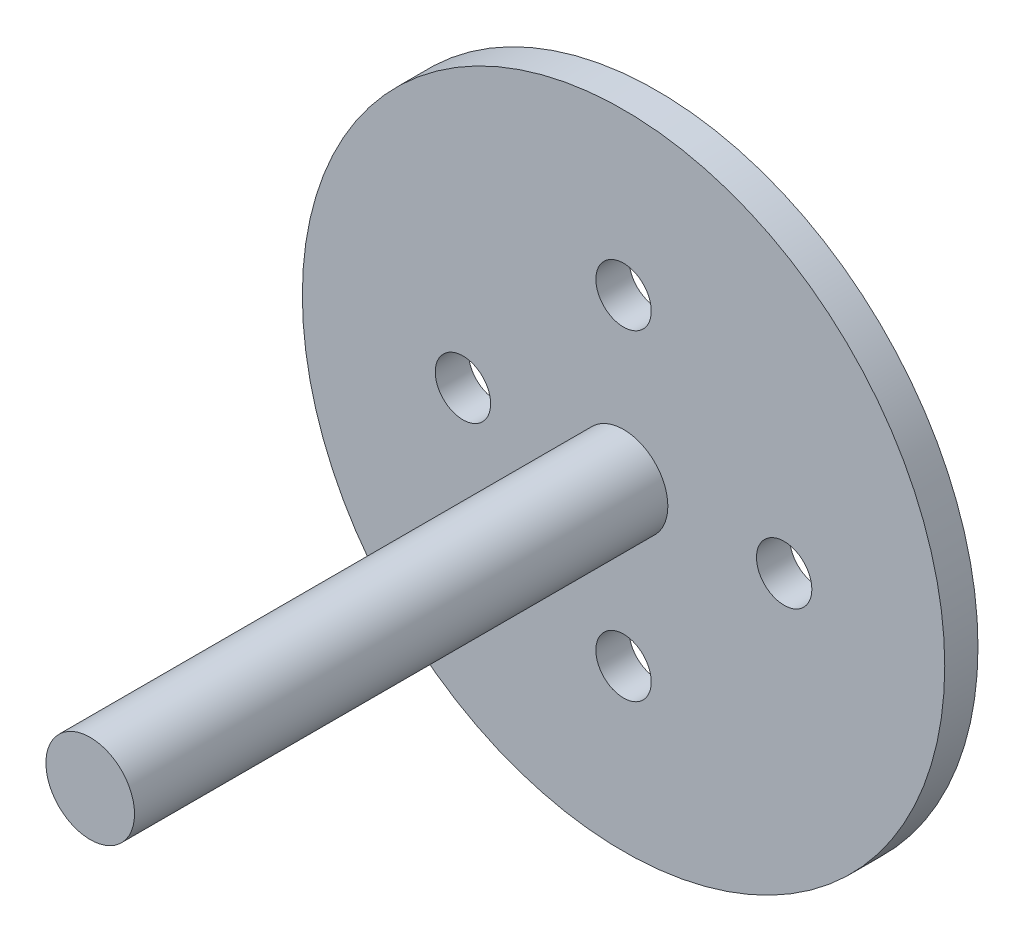
from build123d import *

# Parameters (mm, degrees)
SKETCH1_R           = 29.000000039
SKETCH1_R_2         = 2.5
PLATE_DEPTH         = 3
SKETCH2_R           = 4
MIDDLE_TUBE_DEPTH   = 48.15
BOSS_EXTRUDE3_DEPTH = 2


with BuildPart() as part:
    # Sketch1 → Plate (new body)
    with BuildSketch(Plane.XY):
        Circle(SKETCH1_R)
        with Locations((14.50000002, 0)):
            Circle(SKETCH1_R_2, mode=Mode.SUBTRACT)
        with Locations((-14.50000002, 0)):
            Circle(SKETCH1_R_2, mode=Mode.SUBTRACT)
        with Locations((0, 14.50000002)):
            Circle(SKETCH1_R_2, mode=Mode.SUBTRACT)
        with Locations((0, -14.50000002)):
            Circle(SKETCH1_R_2, mode=Mode.SUBTRACT)
    extrude(amount=PLATE_DEPTH)

    # Sketch2 → Middle_tube (add)
    with BuildSketch(Plane.XY.offset(3)):
        Circle(SKETCH2_R)
    extrude(amount=MIDDLE_TUBE_DEPTH)

    # Sketch3 → Boss-Extrude3 (add)
    with BuildSketch(Plane(origin=(0, 0, 0), x_dir=(-1, 0, 0), z_dir=(0, 0, -1))):
        with BuildLine():
            Line((-11.857625818, 2.176247793), (-11.57268992, 2.176247793))
            Line((-11.57268992, 2.176247793), (-11.57268992, 0.273919067))
            add(Edge.make_bspline(
                [(-11.57268992, 0.273919067), (-11.572732324, 0.2469944), (-11.572812792, 0.195900203), (-11.572275297, 0.123176102), (-11.570770013, 0.0585218), (-11.569820997, 0.001688078), (-11.567709773, -0.047064272), (-11.565987973, -0.087999375), (-11.563774039, -0.120923402), (-11.561113283, -0.140137527), (-11.559969568, -0.148396638)],
                knots=[0, 0, 0, 0, 8.0774e-05, 0.000153283, 0.000218169, 0.000274789, 0.0003238, 0.00036455, 0.00039772, 0.000422728, 0.000422728, 0.000422728, 0.000422728], degree=3))
            add(Edge.make_bspline(
                [(-11.559969568, -0.148396638), (-11.555272873, -0.178193345), (-11.546144125, -0.23610782), (-11.522879197, -0.318574619), (-11.490387607, -0.392898156), (-11.451885704, -0.461397684), (-11.401146835, -0.522166604), (-11.340365057, -0.578147889), (-11.266725224, -0.627108026), (-11.18484596, -0.671876262), (-11.096594352, -0.707858159), (-11.006414131, -0.735066425), (-10.915660857, -0.751647998), (-10.854903908, -0.753568001), (-10.82473319, -0.754521438)],
                knots=[0, 0, 0, 0, 9.0451e-05, 0.000175805, 0.000256145, 0.000333379, 0.000410662, 0.000492593, 0.000580446, 0.000675215, 0.000772184, 0.000865756, 0.00095746, 0.001047918, 0.001047918, 0.001047918, 0.001047918], degree=3))
            add(Edge.make_bspline(
                [(-10.82473319, -0.754521438), (-10.798830868, -0.753547302), (-10.74717583, -0.751604657), (-10.67042571, -0.739574645), (-10.59567704, -0.717893417), (-10.522560709, -0.689917351), (-10.454025174, -0.652953464), (-10.390032194, -0.610253489), (-10.332914911, -0.560169337), (-10.280792298, -0.504742596), (-10.235403464, -0.442204349), (-10.196059642, -0.373916323), (-10.163832549, -0.298850844), (-10.147918066, -0.246096476), (-10.139742204, -0.218994595)],
                knots=[0, 0, 0, 0, 7.7722e-05, 0.000154995, 0.000232312, 0.000310854, 0.000389384, 0.000465414, 0.000541161, 0.000616765, 0.000693219, 0.000772423, 0.000852763, 0.000937642, 0.000937642, 0.000937642, 0.000937642], degree=3))
            add(Edge.make_bspline(
                [(-10.139742204, -0.218994595), (-10.137020662, -0.207792674), (-10.130955969, -0.182830279), (-10.125289007, -0.140628823), (-10.119386659, -0.090836328), (-10.115291299, -0.033095041), (-10.111298763, 0.032401556), (-10.10891019, 0.105994661), (-10.107806167, 0.187417046), (-10.107477164, 0.2442379), (-10.107305305, 0.273919067)],
                knots=[0, 0, 0, 0, 3.4562e-05, 7.7018e-05, 0.000127589, 0.000185003, 0.000250624, 0.000324446, 0.000405866, 0.000494911, 0.000494911, 0.000494911, 0.000494911], degree=3))
            Line((-10.107305305, 0.273919067), (-10.107305305, 2.176247793))
            Line((-10.107305305, 2.176247793), (-9.822369408, 2.176247793))
            Line((-9.822369408, 2.176247793), (-9.822369408, 0.258654644))
            add(Edge.make_bspline(
                [(-9.822369408, 0.258654644), (-9.822599931, 0.224093972), (-9.823049812, 0.156646718), (-9.826951049, 0.057812271), (-9.833171327, -0.035943647), (-9.841959807, -0.124633641), (-9.853604803, -0.207940342), (-9.866554467, -0.286593953), (-9.883045901, -0.360029882), (-9.902307629, -0.428820718), (-9.924327205, -0.494303291), (-9.952848818, -0.556450392), (-9.9849839, -0.617151311), (-10.023097192, -0.675487953), (-10.065924661, -0.731718612), (-10.114412971, -0.785502273), (-10.16695846, -0.837698408), (-10.224434632, -0.886968118), (-10.285894037, -0.932151703), (-10.351153856, -0.971882538), (-10.419712783, -1.005468249), (-10.491392604, -1.033114266), (-10.56622391, -1.053901081), (-10.644208586, -1.069390686), (-10.72552414, -1.078192056), (-10.780827792, -1.079500093), (-10.808832749, -1.080162463)],
                knots=[0, 0, 0, 0, 0.000103679, 0.000202335, 0.00029668, 0.000385534, 0.000469635, 0.000548998, 0.000624606, 0.000695284, 0.00076327, 0.000831594, 0.000900171, 0.000969149, 0.001040386, 0.001112008, 0.001186215, 0.001262445, 0.001338899, 0.001414817, 0.001491333, 0.001567636, 0.001644954, 0.001724035, 0.001805931, 0.001889945, 0.001889945, 0.001889945, 0.001889945], degree=3))
            add(Edge.make_bspline(
                [(-10.808832749, -1.080162463), (-10.839375435, -1.079450569), (-10.899300075, -1.078053835), (-10.987599608, -1.07005034), (-11.072248915, -1.054975083), (-11.154142032, -1.035779991), (-11.232164025, -1.009306172), (-11.307360221, -0.978374302), (-11.378442739, -0.940385644), (-11.446564749, -0.89811878), (-11.509905778, -0.850562144), (-11.568051279, -0.798727844), (-11.621097247, -0.743446216), (-11.668149565, -0.684118741), (-11.709987796, -0.621206835), (-11.746028775, -0.554532525), (-11.776974361, -0.484121624), (-11.792946032, -0.435178364), (-11.801020249, -0.410435901)],
                knots=[0, 0, 0, 0, 9.1642e-05, 0.000179801, 0.000265647, 0.00034941, 0.000431872, 0.000512549, 0.000593062, 0.000673357, 0.000752859, 0.000830344, 0.000906819, 0.000982409, 0.001057203, 0.00113319, 0.001209523, 0.001287564, 0.001287564, 0.001287564, 0.001287564], degree=3))
            add(Edge.make_bspline(
                [(-11.801020249, -0.410435901), (-11.805716671, -0.393533494), (-11.815903315, -0.356871797), (-11.826811978, -0.296196197), (-11.835982359, -0.226332664), (-11.844605258, -0.147276418), (-11.849693384, -0.058966182), (-11.854154204, 0.038559764), (-11.857657244, 0.145419343), (-11.857636586, 0.219854511), (-11.857625818, 0.258654644)],
                knots=[0, 0, 0, 0, 5.2605e-05, 0.000114102, 0.000184711, 0.00026401, 0.000352601, 0.000450014, 0.000556912, 0.000673305, 0.000673305, 0.000673305, 0.000673305], degree=3))
            Line((-11.857625818, 0.258654644), (-11.857625818, 2.176247793))
        make_face()
        with BuildLine():
            Line((-9.008266843, 2.176247793), (-8.388785674, 2.176247793))
            add(Edge.make_bspline(
                [(-8.388785674, 2.176247793), (-8.358461268, 2.176088362), (-8.299685024, 2.175779346), (-8.21421453, 2.170986791), (-8.134160252, 2.164452034), (-8.059498973, 2.154083307), (-7.990265193, 2.141572195), (-7.926250265, 2.126421261), (-7.867657751, 2.108254262), (-7.797705483, 2.079365135), (-7.717948884, 2.036436261), (-7.631590342, 1.973001063), (-7.557745068, 1.8954109), (-7.494076051, 1.807887348), (-7.443456464, 1.711607041), (-7.406835745, 1.608864777), (-7.3836511, 1.500985768), (-7.381266735, 1.426923742), (-7.380061715, 1.389493987)],
                knots=[0, 0, 0, 0, 9.0959e-05, 0.000176302, 0.000256745, 0.000331852, 0.000402335, 0.000467743, 0.000529095, 0.000586142, 0.000694565, 0.000800018, 0.00090617, 0.001014562, 0.001123809, 0.001231237, 0.001341005, 0.001453163, 0.001453163, 0.001453163, 0.001453163], degree=3))
            add(Edge.make_bspline(
                [(-7.380061715, 1.389493987), (-7.381053421, 1.354430597), (-7.383002215, 1.28552773), (-7.401637432, 1.184749502), (-7.430811753, 1.088818039), (-7.471365801, 0.998083447), (-7.524072611, 0.914595812), (-7.586536943, 0.837681649), (-7.661899471, 0.770597476), (-7.718362982, 0.733093557), (-7.747043887, 0.714043266)],
                knots=[0, 0, 0, 0, 0.000105099, 0.000206529, 0.000306317, 0.000405381, 0.000503676, 0.000601724, 0.00070171, 0.000804929, 0.000804929, 0.000804929, 0.000804929], degree=3))
            add(Edge.make_bspline(
                [(-7.747043887, 0.714043266), (-7.710975499, 0.700195731), (-7.641967738, 0.673701967), (-7.54700257, 0.626861225), (-7.46518296, 0.575914167), (-7.395879835, 0.520277418), (-7.336609248, 0.460307282), (-7.28485408, 0.395124428), (-7.240693119, 0.323878555), (-7.202853538, 0.247312491), (-7.173327166, 0.166208052), (-7.151214739, 0.081325991), (-7.138544267, -0.00702932), (-7.136741193, -0.067159629), (-7.135830946, -0.097515228)],
                knots=[0, 0, 0, 0, 0.000115862, 0.000221672, 0.000317136, 0.000404447, 0.000487649, 0.000569596, 0.000653599, 0.000738647, 0.000825372, 0.000912066, 0.001001383, 0.001092443, 0.001092443, 0.001092443, 0.001092443], degree=3))
            add(Edge.make_bspline(
                [(-7.135830946, -0.097515228), (-7.136717085, -0.128509462), (-7.138460588, -0.189491485), (-7.151323848, -0.2790765), (-7.173103538, -0.364688059), (-7.203103792, -0.446879903), (-7.242258178, -0.525493025), (-7.289908545, -0.600616486), (-7.346724321, -0.671495486), (-7.410281352, -0.73891763), (-7.482183441, -0.79953998), (-7.559758447, -0.853529228), (-7.643983323, -0.897930299), (-7.733474775, -0.935228404), (-7.82923669, -0.96371922), (-7.930839056, -0.983651483), (-8.038194244, -0.997081767), (-8.111863089, -0.998185945), (-8.149643045, -0.998752207)],
                knots=[0, 0, 0, 0, 9.2965e-05, 0.000182912, 0.000270839, 0.000357564, 0.000444886, 0.000533812, 0.000623905, 0.000717027, 0.000811331, 0.000905539, 0.001000006, 0.001096388, 0.001195991, 0.001299146, 0.001406751, 0.001520027, 0.001520027, 0.001520027, 0.001520027], degree=3))
            Line((-8.149643045, -0.998752207), (-9.008266843, -0.998752207))
            Line((-9.008266843, -0.998752207), (-9.008266843, 2.176247793))
        make_face()
        with BuildLine():
            Line((-8.723330946, 1.850606768), (-8.723330946, 0.832978562))
            Line((-8.723330946, 0.832978562), (-8.53188964, 0.832978562))
            add(Edge.make_bspline(
                [(-8.53188964, 0.832978562), (-8.503905376, 0.83334135), (-8.449834074, 0.834042329), (-8.371529596, 0.836050305), (-8.298844758, 0.841672816), (-8.231905024, 0.847293711), (-8.170815807, 0.856432801), (-8.115712447, 0.867311369), (-8.065730148, 0.878816576), (-8.008090704, 0.898383182), (-7.942710243, 0.927300788), (-7.873011642, 0.97217881), (-7.811566801, 1.025631616), (-7.759680781, 1.087309132), (-7.71721609, 1.155223457), (-7.687721505, 1.228290985), (-7.667721469, 1.304690676), (-7.665914866, 1.357140091), (-7.664997613, 1.383769828)],
                knots=[0, 0, 0, 0, 8.3964e-05, 0.000162235, 0.00023492, 0.000302637, 0.000363711, 0.000420091, 0.000471151, 0.00051741, 0.000602525, 0.000684916, 0.00076515, 0.000845934, 0.000925893, 0.001004319, 0.001081603, 0.001161311, 0.001161311, 0.001161311, 0.001161311], degree=3))
            add(Edge.make_bspline(
                [(-7.664997613, 1.383769828), (-7.665474933, 1.401391778), (-7.66641125, 1.435959157), (-7.674079603, 1.486350357), (-7.687113045, 1.533742904), (-7.703853726, 1.578786276), (-7.72724775, 1.620072025), (-7.754791749, 1.659027639), (-7.788070911, 1.694326489), (-7.825950759, 1.72731882), (-7.869501438, 1.756569213), (-7.918696967, 1.782187619), (-7.974202932, 1.802816752), (-8.035083879, 1.820883548), (-8.102276937, 1.833572929), (-8.17500671, 1.844144216), (-8.253868919, 1.849526061), (-8.30842912, 1.850238497), (-8.336632228, 1.850606768)],
                knots=[0, 0, 0, 0, 5.2851e-05, 0.000103672, 0.000152426, 0.000200145, 0.000247403, 0.000294352, 0.000342957, 0.000392558, 0.000444773, 0.00049996, 0.000558547, 0.000622148, 0.000690253, 0.000763469, 0.000842543, 0.000927155, 0.000927155, 0.000927155, 0.000927155], degree=3))
            Line((-8.336632228, 1.850606768), (-8.723330946, 1.850606768))
        make_face(mode=Mode.SUBTRACT)
        with BuildLine():
            Line((-8.723330946, 0.507337537), (-8.723330946, -0.673111181))
            Line((-8.723330946, -0.673111181), (-8.317551699, -0.673111181))
            add(Edge.make_bspline(
                [(-8.317551699, -0.673111181), (-8.288505959, -0.672763067), (-8.232524125, -0.672092124), (-8.15169658, -0.669901778), (-8.076781908, -0.6649195), (-8.008121956, -0.657076479), (-7.944975331, -0.648568886), (-7.888099557, -0.637128652), (-7.837033589, -0.624021381), (-7.777820467, -0.603761096), (-7.711142285, -0.57228644), (-7.639286722, -0.524829964), (-7.575400081, -0.46829382), (-7.521148168, -0.402860776), (-7.476686385, -0.331712358), (-7.444341794, -0.256287648), (-7.424392945, -0.17783292), (-7.421977977, -0.124341688), (-7.420766843, -0.097515228)],
                knots=[0, 0, 0, 0, 8.7144e-05, 0.000167958, 0.000242546, 0.000312291, 0.000375253, 0.000433628, 0.000486234, 0.000533299, 0.000621212, 0.00070659, 0.000790835, 0.000876178, 0.000960721, 0.001041645, 0.001121551, 0.001201941, 0.001201941, 0.001201941, 0.001201941], degree=3))
            add(Edge.make_bspline(
                [(-7.420766843, -0.097515228), (-7.42101731, -0.080739126), (-7.421514202, -0.047457522), (-7.429007759, 0.001451828), (-7.439906056, 0.048828156), (-7.453995285, 0.094800106), (-7.474514373, 0.138536526), (-7.498468882, 0.180902419), (-7.526555296, 0.22195379), (-7.570319646, 0.273853477), (-7.633975661, 0.333649624), (-7.72442395, 0.392194359), (-7.82726882, 0.439409155), (-7.901860903, 0.459456537), (-7.940393246, 0.469812497)],
                knots=[0, 0, 0, 0, 5.0282e-05, 9.9752e-05, 0.000148043, 0.000196116, 0.000243648, 0.000292638, 0.000342035, 0.000392605, 0.000496106, 0.000602654, 0.000714508, 0.000834032, 0.000834032, 0.000834032, 0.000834032], degree=3))
            add(Edge.make_bspline(
                [(-7.940393246, 0.469812497), (-7.955841068, 0.472946751), (-7.989335134, 0.479742462), (-8.043952011, 0.486915879), (-8.106305263, 0.493306755), (-8.176538873, 0.498034019), (-8.254741701, 0.502920384), (-8.341080763, 0.504820686), (-8.43520347, 0.507087871), (-8.500510836, 0.507252186), (-8.53443371, 0.507337537)],
                knots=[0, 0, 0, 0, 4.7275e-05, 0.000102503, 0.000165156, 0.000235303, 0.00031366, 0.000400195, 0.000494345, 0.00059611, 0.00059611, 0.00059611, 0.00059611], degree=3))
            Line((-8.53443371, 0.507337537), (-8.723330946, 0.507337537))
        make_face(mode=Mode.SUBTRACT)
        with BuildLine():
            Line((-3.553779664, 1.593655646), (-3.803098574, 1.402850357))
            add(Edge.make_bspline(
                [(-3.803098574, 1.402850357), (-3.820883916, 1.42404663), (-3.856214814, 1.466153403), (-3.913055662, 1.525280562), (-3.972293581, 1.580675477), (-4.033905927, 1.63260204), (-4.099001699, 1.679244391), (-4.166003995, 1.723033178), (-4.236033651, 1.762283197), (-4.332872724, 1.80987462), (-4.459553272, 1.859537204), (-4.619024305, 1.901177992), (-4.785495087, 1.927685773), (-4.899067195, 1.930556736), (-4.956834552, 1.932017024)],
                knots=[0, 0, 0, 0, 8.299e-05, 0.000164861, 0.000245858, 0.000326233, 0.000406381, 0.000485944, 0.000566254, 0.000647036, 0.000809554, 0.000973391, 0.001140702, 0.001313896, 0.001313896, 0.001313896, 0.001313896], degree=3))
            add(Edge.make_bspline(
                [(-4.956834552, 1.932017024), (-4.988660116, 1.931650572), (-5.052015874, 1.93092107), (-5.146039846, 1.921297078), (-5.238308114, 1.90777048), (-5.328760658, 1.887699651), (-5.417282342, 1.862324489), (-5.504451878, 1.832002864), (-5.589007208, 1.794488116), (-5.672118038, 1.753024195), (-5.751746323, 1.706190727), (-5.827089116, 1.655106472), (-5.89787163, 1.600343078), (-5.964149857, 1.541695288), (-6.025991553, 1.479427224), (-6.082948613, 1.412875286), (-6.13482395, 1.342252243), (-6.182645822, 1.268489366), (-6.225474516, 1.191801512), (-6.261333764, 1.111904841), (-6.29308841, 1.030167547), (-6.318215581, 0.945666137), (-6.338104249, 0.8589952), (-6.351827201, 0.769922128), (-6.361341743, 0.678633004), (-6.362067618, 0.616757413), (-6.36243351, 0.585567705)],
                knots=[0, 0, 0, 0, 9.5437e-05, 0.000189987, 0.000283265, 0.000375086, 0.000467691, 0.000559419, 0.000651703, 0.000744998, 0.000837935, 0.000928607, 0.001017915, 0.001106228, 0.001193927, 0.001280987, 0.00136876, 0.001456615, 0.001544584, 0.001631962, 0.001719133, 0.001807466, 0.001896183, 0.00198569, 0.002077709, 0.002171238, 0.002171238, 0.002171238, 0.002171238], degree=3))
            add(Edge.make_bspline(
                [(-6.36243351, 0.585567705), (-6.36128886, 0.538640008), (-6.359041491, 0.446503699), (-6.339040503, 0.311547502), (-6.308646598, 0.182260891), (-6.263093896, 0.059452034), (-6.206924472, -0.058393405), (-6.13594906, -0.169281508), (-6.053746916, -0.274887963), (-5.959155121, -0.372716923), (-5.855372702, -0.462082945), (-5.744022811, -0.540778115), (-5.625382778, -0.606378045), (-5.500762549, -0.660966225), (-5.369203146, -0.702927685), (-5.230941147, -0.732467997), (-5.086277265, -0.751737689), (-4.987426453, -0.753582535), (-4.937118005, -0.754521438)],
                knots=[0, 0, 0, 0, 0.000140704, 0.000276253, 0.000408455, 0.000538433, 0.000668431, 0.000799358, 0.000932567, 0.001069312, 0.00120687, 0.001342915, 0.001477586, 0.00161288, 0.00175046, 0.001891054, 0.002036604, 0.002187448, 0.002187448, 0.002187448, 0.002187448], degree=3))
            add(Edge.make_bspline(
                [(-4.937118005, -0.754521438), (-4.881689137, -0.752989473), (-4.772591866, -0.749974201), (-4.61260087, -0.724429739), (-4.459442712, -0.683011485), (-4.313109151, -0.625046941), (-4.174012722, -0.549694858), (-4.041935752, -0.458347498), (-3.916766755, -0.350135939), (-3.841499949, -0.26751053), (-3.803098574, -0.225354771)],
                knots=[0, 0, 0, 0, 0.000166206, 0.000327134, 0.000484664, 0.00064139, 0.000798189, 0.000958205, 0.001122325, 0.001293282, 0.001293282, 0.001293282, 0.001293282], degree=3))
            Line((-3.803098574, -0.225354771), (-3.553779664, -0.414252007))
            add(Edge.make_bspline(
                [(-3.553779664, -0.414252007), (-3.573843949, -0.440140459), (-3.613876413, -0.491793361), (-3.678699043, -0.564611269), (-3.746986306, -0.633104215), (-3.819245414, -0.696719986), (-3.894645125, -0.756731537), (-3.974539294, -0.811433912), (-4.057877631, -0.861590643), (-4.144377765, -0.907516496), (-4.233947792, -0.948262856), (-4.326480387, -0.983145917), (-4.421576695, -1.013194924), (-4.519241063, -1.037916323), (-4.619676071, -1.057212235), (-4.722519287, -1.070111512), (-4.827992674, -1.07894882), (-4.899150249, -1.079754286), (-4.935209952, -1.080162463)],
                knots=[0, 0, 0, 0, 9.8237e-05, 0.000196004, 0.000292247, 0.000388218, 0.000484669, 0.00058117, 0.000678466, 0.000776338, 0.000874822, 0.000973456, 0.001072826, 0.001173865, 0.001275526, 0.001379423, 0.001484691, 0.001592844, 0.001592844, 0.001592844, 0.001592844], degree=3))
            add(Edge.make_bspline(
                [(-4.935209952, -1.080162463), (-4.969358136, -1.079924799), (-5.036881941, -1.079454846), (-5.136575808, -1.071841951), (-5.233630642, -1.061455404), (-5.327769053, -1.045816143), (-5.419504759, -1.02736092), (-5.508006146, -1.002621994), (-5.594144087, -0.974909536), (-5.67757251, -0.942338584), (-5.758362381, -0.905584618), (-5.836253124, -0.864045132), (-5.911208916, -0.818069441), (-5.983966691, -0.768670967), (-6.053451642, -0.714262986), (-6.120265911, -0.655601111), (-6.184784158, -0.592883058), (-6.224700879, -0.547657584), (-6.244770249, -0.524919074)],
                knots=[0, 0, 0, 0, 0.000102417, 0.000202516, 0.000299794, 0.000395154, 0.000488707, 0.000580357, 0.000670665, 0.000760075, 0.000848874, 0.000936794, 0.001024712, 0.001112565, 0.001200478, 0.001289268, 0.001379219, 0.001470177, 0.001470177, 0.001470177, 0.001470177], degree=3))
            add(Edge.make_bspline(
                [(-6.244770249, -0.524919074), (-6.27691544, -0.485420995), (-6.340817737, -0.406901694), (-6.422574607, -0.279642268), (-6.49255846, -0.146774678), (-6.549142331, -0.007600886), (-6.593377096, 0.137566815), (-6.624021466, 0.288801604), (-6.643934707, 0.445962237), (-6.646211898, 0.552857038), (-6.647369408, 0.607192304)],
                knots=[0, 0, 0, 0, 0.000152677, 0.000303511, 0.000452867, 0.000602629, 0.000753527, 0.000907451, 0.001065071, 0.001228016, 0.001228016, 0.001228016, 0.001228016], degree=3))
            add(Edge.make_bspline(
                [(-6.647369408, 0.607192304), (-6.645958625, 0.664301894), (-6.643182998, 0.776661447), (-6.619601098, 0.941556391), (-6.581665475, 1.099536588), (-6.527784012, 1.250307128), (-6.459471301, 1.394661025), (-6.375082872, 1.531495547), (-6.275599108, 1.661685786), (-6.161800243, 1.783256311), (-6.037007017, 1.894417009), (-5.903367807, 1.992212637), (-5.761144184, 2.073599241), (-5.61190299, 2.141631474), (-5.454526693, 2.193923237), (-5.289351066, 2.230529342), (-5.116686479, 2.253314154), (-4.998882707, 2.256194522), (-4.939026058, 2.25765805)],
                knots=[0, 0, 0, 0, 0.000171259, 0.000336941, 0.000498606, 0.000657931, 0.000816392, 0.000976852, 0.001139297, 0.001307149, 0.001475639, 0.001640004, 0.001802988, 0.001966374, 0.002131298, 0.002299486, 0.002473278, 0.002652798, 0.002652798, 0.002652798, 0.002652798], degree=3))
            add(Edge.make_bspline(
                [(-4.939026058, 2.25765805), (-4.902545787, 2.257220681), (-4.830336765, 2.256354955), (-4.723518287, 2.247912955), (-4.619521319, 2.233839898), (-4.518274214, 2.214684606), (-4.419284412, 2.190910821), (-4.323308479, 2.159940693), (-4.229783242, 2.124528983), (-4.139298547, 2.083745232), (-4.052288533, 2.037964688), (-3.968780302, 1.987694801), (-3.88943718, 1.932997891), (-3.813700867, 1.874339154), (-3.742838304, 1.810477603), (-3.674837535, 1.743169784), (-3.612007842, 1.670476958), (-3.573224587, 1.619309625), (-3.553779664, 1.593655646)],
                knots=[0, 0, 0, 0, 0.000109425, 0.000216595, 0.000321206, 0.000424117, 0.000525619, 0.000626393, 0.000726442, 0.000825506, 0.000923941, 0.001021237, 0.001117738, 0.001212903, 0.001308399, 0.001403742, 0.001499772, 0.001596332, 0.001596332, 0.001596332, 0.001596332], degree=3))
        make_face()
        with BuildLine():
            Line((-1.681343767, 2.176247793), (-1.045962156, 2.176247793))
            add(Edge.make_bspline(
                [(-1.045962156, 2.176247793), (-1.003561275, 2.176106654), (-0.922146887, 2.175835652), (-0.805512563, 2.174324568), (-0.699533697, 2.169993545), (-0.604265699, 2.166266473), (-0.51971032, 2.159470212), (-0.445608277, 2.152974482), (-0.382300866, 2.144471232), (-0.343977844, 2.13657417), (-0.326626218, 2.132998594)],
                knots=[0, 0, 0, 0, 0.000127205, 0.000244248, 0.000349896, 0.000445402, 0.000530231, 0.00060434, 0.000668562, 0.000721699, 0.000721699, 0.000721699, 0.000721699], degree=3))
            add(Edge.make_bspline(
                [(-0.326626218, 2.132998594), (-0.303397352, 2.127259314), (-0.257435155, 2.115903189), (-0.191259023, 2.091900551), (-0.128199601, 2.064124177), (-0.068518832, 2.031499945), (-0.01251565, 1.993785681), (0.040387389, 1.951632455), (0.090430345, 1.905270919), (0.135589396, 1.85353217), (0.178169821, 1.799251907), (0.214082361, 1.740556356), (0.245039953, 1.679177685), (0.269687494, 1.61449167), (0.289533941, 1.547125634), (0.303527744, 1.476469369), (0.311919893, 1.40284477), (0.31277429, 1.352627239), (0.313207515, 1.32716426)],
                knots=[0, 0, 0, 0, 7.1738e-05, 0.000141945, 0.000210849, 0.000278309, 0.000345694, 0.000413139, 0.000481086, 0.000550014, 0.000618962, 0.000687796, 0.000756061, 0.000824921, 0.000895163, 0.000966511, 0.001040751, 0.001117115, 0.001117115, 0.001117115, 0.001117115], degree=3))
            add(Edge.make_bspline(
                [(0.313207515, 1.32716426), (0.311874924, 1.284859557), (0.309274694, 1.202312127), (0.285031207, 1.082514041), (0.24531965, 0.970763734), (0.190597809, 0.867201913), (0.12091157, 0.773847256), (0.037159796, 0.6918502), (-0.060704238, 0.623233994), (-0.151807974, 0.575651807), (-0.232284427, 0.54517824), (-0.298536075, 0.523736685), (-0.370805404, 0.507170474), (-0.448399987, 0.492329497), (-0.531642731, 0.481124746), (-0.620334124, 0.472918192), (-0.714537419, 0.467789163), (-0.779252146, 0.467025344), (-0.812543686, 0.466632409)],
                knots=[0, 0, 0, 0, 0.000126797, 0.000247415, 0.000364897, 0.000481551, 0.000597433, 0.000713022, 0.000831615, 0.000954788, 0.001020224, 0.001089619, 0.001163513, 0.001242474, 0.001326575, 0.001415367, 0.001509635, 0.001609508, 0.001609508, 0.001609508, 0.001609508], degree=3))
            Line((-0.812543686, 0.466632409), (0.353912644, -0.998752207))
            Line((0.353912644, -0.998752207), (0.001558878, -0.998752207))
            Line((0.001558878, -0.998752207), (-1.164897452, 0.466632409))
            Line((-1.164897452, 0.466632409), (-1.396407869, 0.466632409))
            Line((-1.396407869, 0.466632409), (-1.396407869, -0.998752207))
            Line((-1.396407869, -0.998752207), (-1.681343767, -0.998752207))
            Line((-1.681343767, -0.998752207), (-1.681343767, 2.176247793))
        make_face()
        with BuildLine():
            Line((-1.396407869, 1.850606768), (-1.396407869, 0.792273434))
            Line((-1.396407869, 0.792273434), (-0.815087757, 0.787821311))
            add(Edge.make_bspline(
                [(-0.815087757, 0.787821311), (-0.787946007, 0.787809303), (-0.735337566, 0.787786029), (-0.659227677, 0.791408955), (-0.588361576, 0.795530394), (-0.523010322, 0.801834443), (-0.463144722, 0.809958879), (-0.408794697, 0.820121586), (-0.359871529, 0.831961672), (-0.302813569, 0.850287432), (-0.239099001, 0.879321463), (-0.169855462, 0.921563023), (-0.110889056, 0.974693581), (-0.061070709, 1.035448073), (-0.021039011, 1.10224667), (0.007184067, 1.174288662), (0.025093282, 1.249755326), (0.027205606, 1.301624038), (0.028271618, 1.327800277)],
                knots=[0, 0, 0, 0, 8.1413e-05, 0.000157801, 0.000228539, 0.000294357, 0.000354712, 0.000409723, 0.000460165, 0.000505621, 0.000589315, 0.00066961, 0.000747992, 0.000826171, 0.000904597, 0.000980539, 0.001057529, 0.001135968, 0.001135968, 0.001135968, 0.001135968], degree=3))
            add(Edge.make_bspline(
                [(0.028271618, 1.327800277), (0.027181123, 1.35333324), (0.025020158, 1.403930257), (0.007377347, 1.478003833), (-0.022458021, 1.547914566), (-0.062664622, 1.613378063), (-0.11164957, 1.672801124), (-0.169087871, 1.723643898), (-0.233409013, 1.76559877), (-0.293526457, 1.792408815), (-0.34726035, 1.80884611), (-0.393914398, 1.820413237), (-0.44662981, 1.829706434), (-0.505662548, 1.837152318), (-0.570760599, 1.84355216), (-0.642253118, 1.847862702), (-0.719665768, 1.850415279), (-0.773320485, 1.850541453), (-0.801095369, 1.850606768)],
                knots=[0, 0, 0, 0, 7.6536e-05, 0.000151667, 0.000226914, 0.000303706, 0.000381394, 0.000457083, 0.00053294, 0.00061095, 0.000653596, 0.000701416, 0.000755061, 0.00081407, 0.000879888, 0.000951261, 0.001028897, 0.001112218, 0.001112218, 0.001112218, 0.001112218], degree=3))
            Line((-0.801095369, 1.850606768), (-1.396407869, 1.850606768))
        make_face(mode=Mode.SUBTRACT)
        with BuildLine():
            add(Edge.make_bspline(
                [(2.490931874, 2.25765805), (2.549722085, 2.256168993), (2.665190908, 2.253244364), (2.834894566, 2.230856891), (2.996905831, 2.192126073), (3.152544457, 2.140543225), (3.2999488, 2.071732461), (3.440228366, 1.988560934), (3.573049388, 1.890157289), (3.696621641, 1.777282205), (3.809703303, 1.654470071), (3.909331071, 1.523407967), (3.99282658, 1.384888339), (4.061393687, 1.239327443), (4.115185998, 1.087054472), (4.152305416, 0.927257627), (4.176016452, 0.760972272), (4.178788479, 0.647555045), (4.180194695, 0.590019828)],
                knots=[0, 0, 0, 0, 0.000176342, 0.00034635, 0.000512345, 0.00067546, 0.000837376, 0.000999356, 0.00116396, 0.001332355, 0.001500709, 0.001664166, 0.001825381, 0.001984993, 0.002146116, 0.00230887, 0.002476442, 0.002648971, 0.002648971, 0.002648971, 0.002648971], degree=3))
            add(Edge.make_bspline(
                [(4.180194695, 0.590019828), (4.178788685, 0.532908431), (4.176017276, 0.420335249), (4.152278456, 0.255105125), (4.115048406, 0.09627285), (4.061893222, -0.05589642), (3.993652966, -0.20156321), (3.90960149, -0.340344233), (3.81059482, -0.472284985), (3.697921462, -0.595940046), (3.575093374, -0.709330608), (3.443348775, -0.808135588), (3.305650549, -0.893156759), (3.160226742, -0.960996234), (3.009005995, -1.015217905), (2.850634887, -1.052186362), (2.685855513, -1.076032466), (2.573486817, -1.078770691), (2.51637258, -1.080162463)],
                knots=[0, 0, 0, 0, 0.000171259, 0.000337571, 0.000499706, 0.000660019, 0.000820206, 0.000981421, 0.001145895, 0.001314289, 0.001482643, 0.001646609, 0.00180761, 0.001967222, 0.002127146, 0.002288662, 0.002454344, 0.002625603, 0.002625603, 0.002625603, 0.002625603], degree=3))
            add(Edge.make_bspline(
                [(2.51637258, -1.080162463), (2.458837662, -1.078756948), (2.345421023, -1.075986303), (2.178926712, -1.052236029), (2.019017616, -1.015096418), (1.866151026, -0.962020001), (1.720241697, -0.89342437), (1.581004265, -0.809781826), (1.44899761, -0.710533919), (1.325316168, -0.597897098), (1.212150824, -0.47527719), (1.113490534, -0.34389183), (1.029829181, -0.206318666), (0.961463872, -0.062175912), (0.907339684, 0.087839611), (0.870414599, 0.244728587), (0.846524128, 0.407596567), (0.843771089, 0.518488339), (0.842374182, 0.574755405)],
                knots=[0, 0, 0, 0, 0.00017253, 0.000340102, 0.000503474, 0.000664388, 0.000824575, 0.000986335, 0.001150809, 0.001319204, 0.001487557, 0.001650632, 0.001811303, 0.001969765, 0.00212849, 0.002288769, 0.002452562, 0.00262128, 0.00262128, 0.00262128, 0.00262128], degree=3))
            add(Edge.make_bspline(
                [(0.842374182, 0.574755405), (0.842859173, 0.612522184), (0.843823036, 0.687579296), (0.855426929, 0.799036855), (0.872265043, 0.908701951), (0.896396778, 1.01626274), (0.92795779, 1.121455919), (0.965197844, 1.225006968), (1.010681846, 1.325866489), (1.062099291, 1.42451228), (1.119486789, 1.519406594), (1.182874076, 1.609104502), (1.250034731, 1.694358692), (1.323661524, 1.772959902), (1.401327871, 1.847194719), (1.484293685, 1.915922327), (1.572052721, 1.979762461), (1.664982594, 2.03729377), (1.760793458, 2.0893267), (1.859560249, 2.13397795), (1.959941568, 2.172301163), (2.06240757, 2.203362483), (2.166686156, 2.227884401), (2.273004918, 2.244582501), (2.381279154, 2.256215989), (2.454223708, 2.257175295), (2.490931874, 2.25765805)],
                knots=[0, 0, 0, 0, 0.000113256, 0.000225083, 0.000335817, 0.000445988, 0.000555461, 0.000665116, 0.000775867, 0.0008871, 0.000998686, 0.001108262, 0.001216432, 0.001323994, 0.001431064, 0.001538557, 0.001646949, 0.001756368, 0.001866213, 0.001973803, 0.002081296, 0.002188332, 0.002294783, 0.002402377, 0.00251104, 0.002621117, 0.002621117, 0.002621117, 0.002621117], degree=3))
        make_face()
        with BuildLine():
            add(Edge.make_bspline(
                [(2.504924262, 1.932017024), (2.474793845, 1.931649731), (2.414821058, 1.930918655), (2.325662943, 1.921288685), (2.237677403, 1.907563714), (2.150846268, 1.887986192), (2.065532848, 1.861312515), (1.980941921, 1.830613977), (1.897844865, 1.793220559), (1.816516008, 1.750972463), (1.737671618, 1.704210228), (1.663274382, 1.652528696), (1.593131698, 1.597139865), (1.527415306, 1.53791447), (1.466318171, 1.474550902), (1.408637763, 1.408009764), (1.356686072, 1.33638912), (1.309074155, 1.261631108), (1.266467615, 1.183833102), (1.228580471, 1.103814156), (1.197588835, 1.02092154), (1.172313679, 0.936054554), (1.151358851, 0.849347608), (1.138083791, 0.760142945), (1.128348008, 0.668888808), (1.127658719, 0.607219555), (1.12731008, 0.576027441)],
                knots=[0, 0, 0, 0, 9.035e-05, 0.000179837, 0.000268716, 0.000357433, 0.000446559, 0.000536708, 0.000627246, 0.000719699, 0.000811541, 0.000902048, 0.000991247, 0.001079509, 0.001167217, 0.001255174, 0.001343459, 0.001432386, 0.001520911, 0.0016094, 0.001697761, 0.001786094, 0.001874954, 0.00196509, 0.002056475, 0.002150004, 0.002150004, 0.002150004, 0.002150004], degree=3))
            add(Edge.make_bspline(
                [(1.12731008, 0.576027441), (1.128466562, 0.530160283), (1.130741719, 0.439925395), (1.150660372, 0.307692864), (1.181341735, 0.180612776), (1.226569488, 0.059380473), (1.283130403, -0.057046127), (1.353004797, -0.167634193), (1.435789824, -0.272413615), (1.529827452, -0.370652895), (1.632627336, -0.46032016), (1.741786312, -0.539026966), (1.856134942, -0.60562055), (1.975971419, -0.659872294), (2.100655972, -0.702861556), (2.230992036, -0.732324315), (2.366111381, -0.751714906), (2.45821419, -0.753577049), (2.504924262, -0.754521438)],
                knots=[0, 0, 0, 0, 0.000137527, 0.000270558, 0.000400289, 0.000529072, 0.000657927, 0.000787976, 0.000920685, 0.001057889, 0.001195382, 0.001329354, 0.001461022, 0.001591668, 0.001723409, 0.001855936, 0.001992028, 0.002132069, 0.002132069, 0.002132069, 0.002132069], degree=3))
            add(Edge.make_bspline(
                [(2.504924262, -0.754521438), (2.536320024, -0.754090087), (2.59858725, -0.75323459), (2.691202474, -0.744617933), (2.782149181, -0.730800451), (2.871299806, -0.710906214), (2.95855317, -0.686007677), (3.044273456, -0.656427809), (3.12754762, -0.619524146), (3.209426187, -0.578749933), (3.28779992, -0.53226779), (3.36261701, -0.482340325), (3.431991649, -0.427033077), (3.497658878, -0.368687632), (3.559006853, -0.30612757), (3.615620717, -0.239434226), (3.667309837, -0.16818663), (3.714903674, -0.093542012), (3.757360919, -0.015531126), (3.794353388, 0.064777939), (3.825737007, 0.147187432), (3.851072151, 0.231816214), (3.870925391, 0.318503556), (3.884605033, 0.407365527), (3.894173973, 0.498224359), (3.894895222, 0.559677714), (3.895258798, 0.590655846)],
                knots=[0, 0, 0, 0, 9.4165e-05, 0.000186757, 0.000278778, 0.000369977, 0.000460573, 0.00055089, 0.000641754, 0.000733627, 0.000825145, 0.000914934, 0.00100324, 0.001091077, 0.00117833, 0.001265874, 0.00135327, 0.001442197, 0.00153128, 0.001619501, 0.001707267, 0.0017956, 0.001884317, 0.001973824, 0.00206521, 0.002158103, 0.002158103, 0.002158103, 0.002158103], degree=3))
            add(Edge.make_bspline(
                [(3.895258798, 0.590655846), (3.894894931, 0.621422053), (3.894173134, 0.682452493), (3.884609603, 0.772677664), (3.870910939, 0.86090022), (3.851169053, 0.946773813), (3.825723557, 1.030320332), (3.794347907, 1.111461311), (3.757349814, 1.19049903), (3.714888068, 1.267238143), (3.667157999, 1.340875226), (3.615002507, 1.411271701), (3.557521084, 1.477105544), (3.496356047, 1.540002017), (3.429979601, 1.598619674), (3.35869242, 1.652977961), (3.283359941, 1.704388717), (3.203597378, 1.750766905), (3.121279648, 1.793596959), (3.036811986, 1.830291797), (2.951151303, 1.86147222), (2.86451543, 1.888066895), (2.776175156, 1.907487037), (2.686727397, 1.921301054), (2.596295906, 1.930915304), (2.535478128, 1.931648618), (2.504924262, 1.932017024)],
                knots=[0, 0, 0, 0, 9.2258e-05, 0.00018301, 0.000271889, 0.000359986, 0.000447102, 0.00053368, 0.000620747, 0.000708715, 0.000796571, 0.000883833, 0.000971308, 0.00105856, 0.001146873, 0.001236684, 0.001327357, 0.001420293, 0.001513311, 0.001605595, 0.001696341, 0.001786684, 0.001877263, 0.001967398, 0.00205815, 0.002149772, 0.002149772, 0.002149772, 0.002149772], degree=3))
        make_face(mode=Mode.SUBTRACT)
        Polygon((4.587245977, 2.176247793), (4.892534439, 2.176247793), (5.950867772, -0.325845556), (7.009201105, 2.176247793), (7.314489567, 2.176247793), (5.971220336, -0.998752207), (5.930515208, -0.998752207), align=None)
        Polygon((7.884361362, 2.176247793), (9.675387003, 2.176247793), (9.675387003, 1.850606768), (8.169297259, 1.850606768), (8.169297259, 0.873683691), (9.675387003, 0.873683691), (9.675387003, 0.548042665), (8.169297259, 0.548042665), (8.169297259, -0.673111181), (9.675387003, -0.673111181), (9.675387003, -0.998752207), (7.884361362, -0.998752207), align=None)
        with BuildLine():
            Line((10.245258798, 2.176247793), (10.880640408, 2.176247793))
            add(Edge.make_bspline(
                [(10.880640408, 2.176247793), (10.923041289, 2.176106654), (11.004455677, 2.175835652), (11.121090001, 2.174324568), (11.227068868, 2.169993545), (11.322336865, 2.166266473), (11.406892244, 2.159470212), (11.480994287, 2.152974482), (11.544301698, 2.144471232), (11.58262472, 2.13657417), (11.599976346, 2.132998594)],
                knots=[0, 0, 0, 0, 0.000127205, 0.000244248, 0.000349896, 0.000445402, 0.000530231, 0.00060434, 0.000668562, 0.000721699, 0.000721699, 0.000721699, 0.000721699], degree=3))
            add(Edge.make_bspline(
                [(11.599976346, 2.132998594), (11.623205212, 2.127259314), (11.669167409, 2.115903189), (11.735343541, 2.091900551), (11.798402963, 2.064124177), (11.858083732, 2.031499945), (11.914086914, 1.993785681), (11.966989953, 1.951632455), (12.01703291, 1.905270919), (12.06219196, 1.85353217), (12.104772385, 1.799251907), (12.140684925, 1.740556356), (12.171642517, 1.679177685), (12.196290058, 1.61449167), (12.216136505, 1.547125634), (12.230130308, 1.476469369), (12.238522457, 1.40284477), (12.239376854, 1.352627239), (12.23981008, 1.32716426)],
                knots=[0, 0, 0, 0, 7.1738e-05, 0.000141945, 0.000210849, 0.000278309, 0.000345694, 0.000413139, 0.000481086, 0.000550014, 0.000618962, 0.000687796, 0.000756061, 0.000824921, 0.000895163, 0.000966511, 0.001040751, 0.001117115, 0.001117115, 0.001117115, 0.001117115], degree=3))
            add(Edge.make_bspline(
                [(12.23981008, 1.32716426), (12.238477488, 1.284859557), (12.235877258, 1.202312127), (12.211633771, 1.082514041), (12.171922214, 0.970763734), (12.117200373, 0.867201913), (12.047514134, 0.773847256), (11.96376236, 0.6918502), (11.865898326, 0.623233994), (11.77479459, 0.575651807), (11.694318137, 0.54517824), (11.628066489, 0.523736685), (11.55579716, 0.507170474), (11.478202578, 0.492329497), (11.394959833, 0.481124746), (11.30626844, 0.472918192), (11.212065145, 0.467789163), (11.147350418, 0.467025344), (11.114058878, 0.466632409)],
                knots=[0, 0, 0, 0, 0.000126797, 0.000247415, 0.000364897, 0.000481551, 0.000597433, 0.000713022, 0.000831615, 0.000954788, 0.001020224, 0.001089619, 0.001163513, 0.001242474, 0.001326575, 0.001415367, 0.001509635, 0.001609508, 0.001609508, 0.001609508, 0.001609508], degree=3))
            Line((11.114058878, 0.466632409), (12.280515208, -0.998752207))
            Line((12.280515208, -0.998752207), (11.928161442, -0.998752207))
            Line((11.928161442, -0.998752207), (10.761705112, 0.466632409))
            Line((10.761705112, 0.466632409), (10.530194695, 0.466632409))
            Line((10.530194695, 0.466632409), (10.530194695, -0.998752207))
            Line((10.530194695, -0.998752207), (10.245258798, -0.998752207))
            Line((10.245258798, -0.998752207), (10.245258798, 2.176247793))
        make_face()
        with BuildLine():
            Line((10.530194695, 1.850606768), (10.530194695, 0.792273434))
            Line((10.530194695, 0.792273434), (11.111514807, 0.787821311))
            add(Edge.make_bspline(
                [(11.111514807, 0.787821311), (11.138656557, 0.787809303), (11.191264998, 0.787786029), (11.267374887, 0.791408955), (11.338240988, 0.795530394), (11.403592242, 0.801834443), (11.463457842, 0.809958879), (11.517807867, 0.820121586), (11.566731036, 0.831961672), (11.623788995, 0.850287432), (11.687503563, 0.879321463), (11.756747102, 0.921563023), (11.815713508, 0.974693581), (11.865531855, 1.035448073), (11.905563553, 1.10224667), (11.933786631, 1.174288662), (11.951695847, 1.249755326), (11.95380817, 1.301624038), (11.954874182, 1.327800277)],
                knots=[0, 0, 0, 0, 8.1413e-05, 0.000157801, 0.000228539, 0.000294357, 0.000354712, 0.000409723, 0.000460165, 0.000505621, 0.000589315, 0.00066961, 0.000747992, 0.000826171, 0.000904597, 0.000980539, 0.001057529, 0.001135968, 0.001135968, 0.001135968, 0.001135968], degree=3))
            add(Edge.make_bspline(
                [(11.954874182, 1.327800277), (11.953783687, 1.35333324), (11.951622722, 1.403930257), (11.933979911, 1.478003833), (11.904144543, 1.547914566), (11.863937942, 1.613378063), (11.814952994, 1.672801124), (11.757514693, 1.723643898), (11.693193551, 1.76559877), (11.633076107, 1.792408815), (11.579342214, 1.80884611), (11.532688166, 1.820413237), (11.479972754, 1.829706434), (11.420940016, 1.837152318), (11.355841966, 1.84355216), (11.284349446, 1.847862702), (11.206936796, 1.850415279), (11.153282079, 1.850541453), (11.125507195, 1.850606768)],
                knots=[0, 0, 0, 0, 7.6536e-05, 0.000151667, 0.000226914, 0.000303706, 0.000381394, 0.000457083, 0.00053294, 0.00061095, 0.000653596, 0.000701416, 0.000755061, 0.00081407, 0.000879888, 0.000951261, 0.001028897, 0.001112218, 0.001112218, 0.001112218, 0.001112218], degree=3))
            Line((11.125507195, 1.850606768), (10.530194695, 1.850606768))
        make_face(mode=Mode.SUBTRACT)
    extrude(amount=BOSS_EXTRUDE3_DEPTH)


solid = part.part
